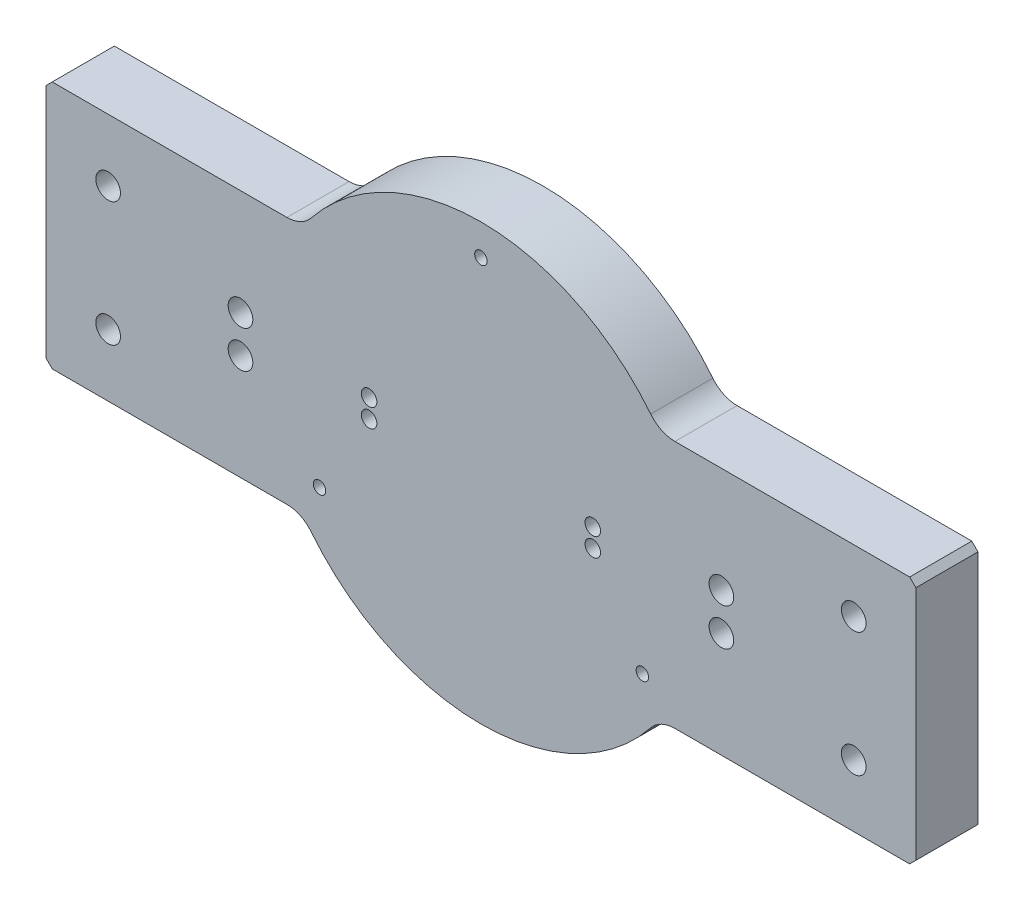
from build123d import *

# Parameters (mm, degrees)
SKETCH1_W               = 355.6
SKETCH1_H               = 101.6
EXTRUDE1_DEPTH          = 25.4
SKETCH10_R              = 88.9
EXTRUDE2_DEPTH          = 25.4
F_10_CLEARANCE_HOLE1_D  = 5.1054
CIRPATTERN1_COUNT       = 3
F_3_8_CLEARANCE_HOLE2_D = 10.0838
LPATTERN1_COUNT         = 2
LPATTERN1_PITCH         = 15.24
LPATTERN1_COUNT_DIR2    = 2
LPATTERN1_PITCH_DIR2    = 196.596
F_3_8_CLEARANCE_HOLE1_D = 10.0838
LPATTERN2_COUNT         = 2
LPATTERN2_PITCH         = 304.8
LPATTERN2_COUNT_DIR2    = 2
LPATTERN2_PITCH_DIR2    = 50.8
LPATTERN3_COUNT         = 2
LPATTERN3_PITCH         = 7.62
LPATTERN3_COUNT_DIR2    = 2
LPATTERN3_PITCH_DIR2    = 91.44
FILLET2_R               = 12.7
CHAMFER1_SIZE           = 2.54


with BuildPart() as part:
    # Sketch1 → Extrude1 (new body)
    with BuildSketch(Plane.XY):
        Rectangle(SKETCH1_W, SKETCH1_H)
    extrude(amount=EXTRUDE1_DEPTH)

    # Sketch10 → Extrude2 (add)
    with BuildSketch(Plane.XY.offset(25.4)):
        Circle(SKETCH10_R)
    extrude(amount=-EXTRUDE2_DEPTH)

    # 10 Clearance Hole1 (through all)
    with Locations(Plane(origin=(0, 0, 0), x_dir=(-1, 0, 0), z_dir=(0, 0, -1))):
        with Locations((0, 76.2)):
            f_10_clearance_hole1 = Hole(F_10_CLEARANCE_HOLE1_D / 2)

    # CirPattern1: 10 Clearance Hole1 ×3 about axis
    cirpattern1_axis = Axis((0, 0, 0), (0, 0, 1))
    for i in range(1, CIRPATTERN1_COUNT):
        add(f_10_clearance_hole1.rotate(cirpattern1_axis, i * 360 / CIRPATTERN1_COUNT), mode=Mode.SUBTRACT)

    # 3_8 Clearance Hole2 (through all)
    with Locations(Plane.XY.offset(25.4)):
        with Locations((98.298, 7.62)):
            f_3_8_clearance_hole2 = Hole(F_3_8_CLEARANCE_HOLE2_D / 2)

    # LPattern1: 3_8 Clearance Hole2 2 × 2
    with Locations(*[(-j * LPATTERN1_PITCH_DIR2, -i * LPATTERN1_PITCH, 0) for i in range(LPATTERN1_COUNT) for j in range(LPATTERN1_COUNT_DIR2) if (i, j) != (0, 0)]):
        add(f_3_8_clearance_hole2, mode=Mode.SUBTRACT)

    # 3_8 Clearance Hole1 (through all)
    with Locations(Plane.XY.offset(25.4)):
        with Locations((-152.4, 25.4)):
            f_3_8_clearance_hole1 = Hole(F_3_8_CLEARANCE_HOLE1_D / 2)

    # LPattern2: 3_8 Clearance Hole1 2 × 2
    with Locations(*[(i * LPATTERN2_PITCH, -j * LPATTERN2_PITCH_DIR2, 0) for i in range(LPATTERN2_COUNT) for j in range(LPATTERN2_COUNT_DIR2) if (i, j) != (0, 0)]):
        add(f_3_8_clearance_hole1, mode=Mode.SUBTRACT)

    # Sketch8 → 1_4 _0.25_ Diameter Hole1 (revolve, cut)
    with BuildSketch(Plane(origin=(45.72, 3.81, 25.4), x_dir=(0, -1, 0), z_dir=(1, 0, 0))):
        Polygon((0, 0), (0, 27.307732465), (3.175, 25.4), (3.175, 0), align=None)
    f_1_4_0_25_diameter_hole1 = revolve(axis=Axis((45.72, 3.81, 31.75), (0, 0, -1)), mode=Mode.SUBTRACT)

    # LPattern3: 1_4 _0.25_ Diameter Hole1 2 × 2
    with Locations(*[(-j * LPATTERN3_PITCH_DIR2, -i * LPATTERN3_PITCH, 0) for i in range(LPATTERN3_COUNT) for j in range(LPATTERN3_COUNT_DIR2) if (i, j) != (0, 0)]):
        add(f_1_4_0_25_diameter_hole1, mode=Mode.SUBTRACT)

    # Fillet2
    fillet2_edges = [part.edges().sort_by_distance(p)[0] for p in [
        (72.955945611, 50.8, 12.7),
        (72.955945611, -50.8, 12.7),
        (-72.955945611, 50.8, 12.7),
        (-72.955945611, -50.8, 12.7),
    ]]
    fillet(fillet2_edges, radius=FILLET2_R)

    # Chamfer1
    chamfer1_edges = [part.edges().sort_by_distance(p)[0] for p in [
        (177.8, -50.8, 12.7),
        (-177.8, -50.8, 12.7),
        (-177.8, 50.8, 12.7),
        (177.8, 50.8, 12.7),
    ]]
    chamfer(chamfer1_edges, length=CHAMFER1_SIZE)


solid = part.part
